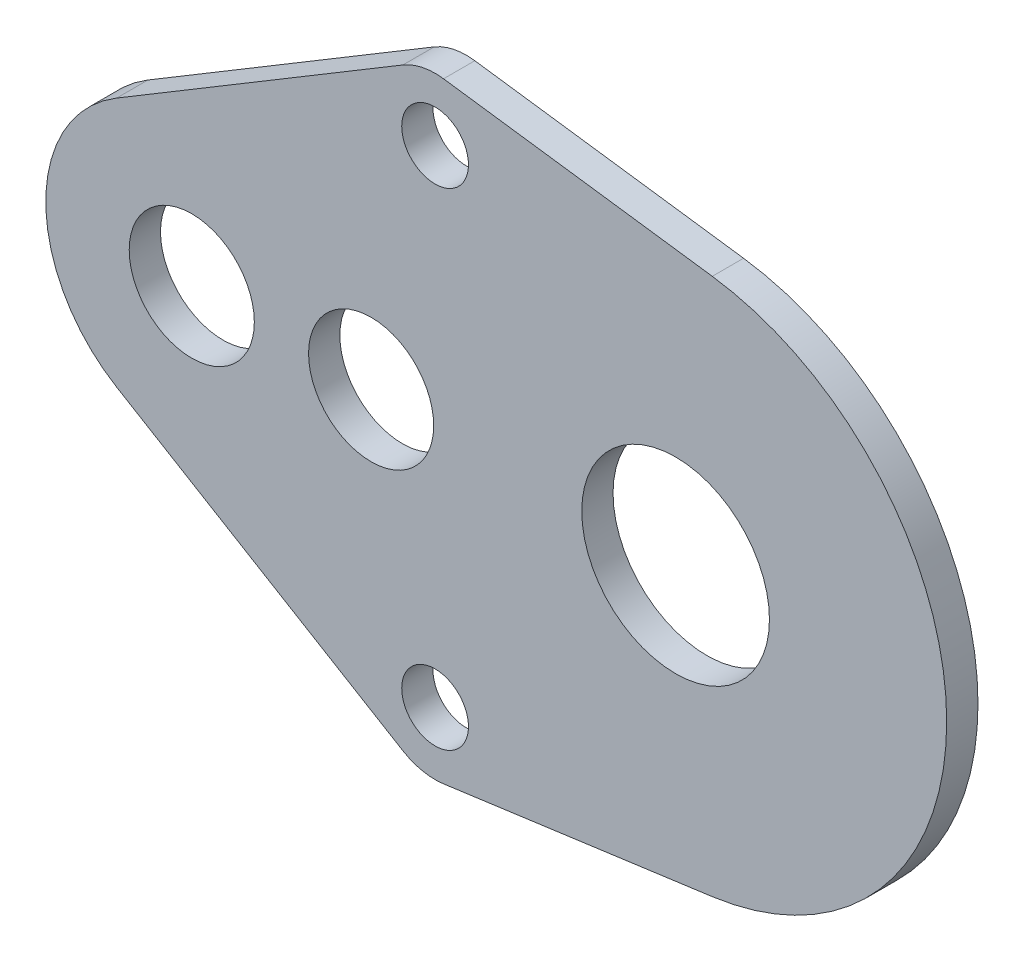
from build123d import *

# Parameters (mm, degrees)
SKETCH1_R           = 3
SKETCH1_R_2         = 4.5
SKETCH1_R_3         = 1.6
BOSS_EXTRUDE3_DEPTH = 1.6
SKETCH2_R           = 1.6
SKETCH2_R_2         = 3
SKETCH2_R_3         = 4.5
BOSS_EXTRUDE4_DEPTH = 1.5
SKETCH3_R           = 63.206562555
CUT_EXTRUDE1_DEPTH  = 1.6
SKETCH4_R           = 3
SKETCH4_R_2         = 1.6
BOSS_EXTRUDE5_DEPTH = 1.5


with BuildPart() as part:
    # Sketch1 → Boss-Extrude3 (new body)
    with BuildSketch(Plane.XY):
        with BuildLine():
            Line((12.073070054, 14.639688463), (24.958502044, 12.880515151))
            ThreePointArc((24.958502044, 12.880515151), (36.2, 0), (24.958502044, -12.880515151))
            Line((24.958502044, -12.880515151), (12.073070054, -14.639688463))
            ThreePointArc((12.073070054, -14.639688463), (11.870633815, -14.660360595), (11.66726189, -14.66726189))
            Line((11.66726189, -14.66726189), (0, -14.66726189))
            ThreePointArc((0, -14.66726189), (-0.888679088, -14.53261518), (-1.697586366, -14.140761542))
            Line((-1.697586366, -14.140761542), (-18.697586366, -2.473499652))
            ThreePointArc((-18.697586366, -2.473499652), (-19.891071988, -0.801063519), (-19.728500117, 1.247111507))
            Line((-19.728500117, 1.247111507), (-14.395762007, 12.914373397))
            ThreePointArc((-14.395762007, 12.914373397), (-13.288783625, 14.191279968), (-11.66726189, 14.66726189))
            Line((-11.66726189, 14.66726189), (11.66726189, 14.66726189))
            ThreePointArc((11.66726189, 14.66726189), (11.870633815, 14.660360595), (12.073070054, 14.639688463))
        make_face()
        Circle(SKETCH1_R, mode=Mode.SUBTRACT)
        with Locations((23.2, 0)):
            Circle(SKETCH1_R_2, mode=Mode.SUBTRACT)
        with Locations((8.6, 0)):
            Circle(SKETCH1_R, mode=Mode.SUBTRACT)
        with Locations((-17, 0)):
            Circle(SKETCH1_R_3, mode=Mode.SUBTRACT)
        with Locations((0, -11.66726189)):
            Circle(SKETCH1_R_3, mode=Mode.SUBTRACT)
        with Locations((11.66726189, -11.66726189)):
            Circle(SKETCH1_R_3, mode=Mode.SUBTRACT)
        with Locations((-11.66726189, 11.66726189)):
            Circle(SKETCH1_R_3, mode=Mode.SUBTRACT)
        with Locations((0, 11.66726189)):
            Circle(SKETCH1_R_3, mode=Mode.SUBTRACT)
        with Locations((11.66726189, 11.66726189)):
            Circle(SKETCH1_R_3, mode=Mode.SUBTRACT)
    extrude(amount=BOSS_EXTRUDE3_DEPTH)

    # Sketch2 → Boss-Extrude4 (add)
    with BuildSketch(Plane.XY.offset(1.6)):
        with BuildLine():
            Line((12.073070054, 14.639688463), (24.958502044, 12.880515151))
            ThreePointArc((24.958502044, 12.880515151), (36.2, 0), (24.958502044, -12.880515151))
            Line((24.958502044, -12.880515151), (12.073070054, -14.639688463))
            ThreePointArc((12.073070054, -14.639688463), (10.884137398, -14.56324463), (9.81871257, -14.030070687))
            Line((9.81871257, -14.030070687), (-3.080915533, -3.938014662))
            ThreePointArc((-3.080915533, -3.938014662), (-5, 0), (-3.080915533, 3.938014662))
            Line((-3.080915533, 3.938014662), (9.81871257, 14.030070687))
            ThreePointArc((9.81871257, 14.030070687), (10.884137398, 14.56324463), (12.073070054, 14.639688463))
        make_face()
        with Locations((11.66726189, 11.66726189)):
            Circle(SKETCH2_R, mode=Mode.SUBTRACT)
        Circle(SKETCH2_R_2, mode=Mode.SUBTRACT)
        with Locations((8.6, 0)):
            Circle(SKETCH2_R_2, mode=Mode.SUBTRACT)
        with Locations((23.2, 0)):
            Circle(SKETCH2_R_3, mode=Mode.SUBTRACT)
        with Locations((11.66726189, -11.66726189)):
            Circle(SKETCH2_R, mode=Mode.SUBTRACT)
    extrude(amount=BOSS_EXTRUDE4_DEPTH)

    # Sketch3 → Cut-Extrude1 (cut)
    with BuildSketch(Plane(origin=(0, 0, 0), x_dir=(-1, 0, 0), z_dir=(0, 0, -1))):
        Circle(SKETCH3_R)
    extrude(amount=-CUT_EXTRUDE1_DEPTH, mode=Mode.SUBTRACT)

    # Sketch4 → Boss-Extrude5 (add)
    with BuildSketch(Plane.XY.offset(3.1)):
        with BuildLine():
            Line((-3.602159399, 6.00203696), (10.12347929, 14.239563444))
            ThreePointArc((10.12347929, 14.239563444), (13.145208472, 14.277946455), (14.66726189, 11.66726189))
            Line((14.66726189, 11.66726189), (14.66726189, -11.66726189))
            ThreePointArc((14.66726189, -11.66726189), (13.145208472, -14.277946455), (10.12347929, -14.239563444))
            Line((10.12347929, -14.239563444), (-3.602159399, -6.00203696))
            ThreePointArc((-3.602159399, -6.00203696), (-7, 0), (-3.602159399, 6.00203696))
        make_face()
        Circle(SKETCH4_R, mode=Mode.SUBTRACT)
        with Locations((8.6, 0)):
            Circle(SKETCH4_R, mode=Mode.SUBTRACT)
        with Locations((11.66726189, 11.66726189)):
            Circle(SKETCH4_R_2, mode=Mode.SUBTRACT)
        with Locations((11.66726189, -11.66726189)):
            Circle(SKETCH4_R_2, mode=Mode.SUBTRACT)
    extrude(amount=-BOSS_EXTRUDE5_DEPTH)


solid = part.part
